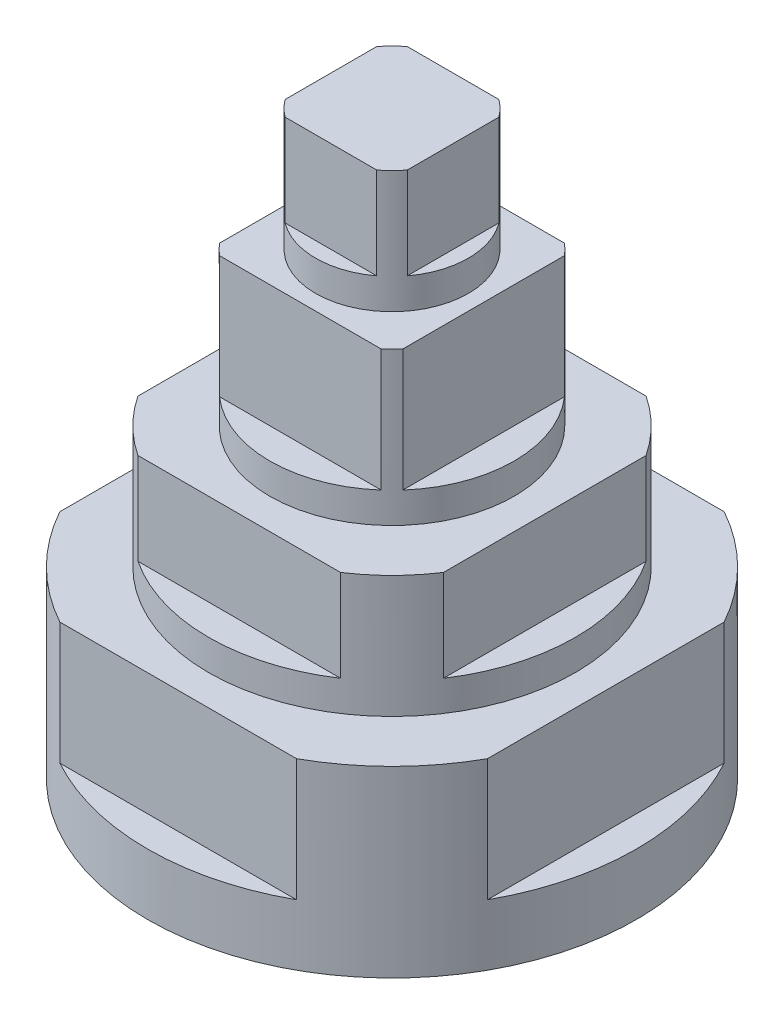
from build123d import *

# Parameters (mm, degrees)
SKETCH1_R           = 40
BOSS_EXTRUDE1_DEPTH = 30
SKETCH2_R           = 30
BOSS_EXTRUDE2_DEPTH = 20
SKETCH3_R           = 20
BOSS_EXTRUDE3_DEPTH = 25
SKETCH4_R           = 12.5
BOSS_EXTRUDE4_DEPTH = 20
SKETCH5_OUTSIDE_W   = 111.546
SKETCH5_OUTSIDE_H   = 111.546
SKETCH5_OUTSIDE_W_2 = 20
SKETCH5_OUTSIDE_H_2 = 20
CUT_EXTRUDE2_DEPTH  = 15
CUT_EXTRUDE7_DEPTH  = 20
CUT_EXTRUDE8_START  = 50
CUT_EXTRUDE8_DEPTH  = 15
CUT_EXTRUDE9_DEPTH  = 20


with BuildPart() as part:
    # Sketch1 → Boss-Extrude1 (new body)
    with BuildSketch(Plane(origin=(0, 0, 0), x_dir=(1, 0, 0), z_dir=(0, 1, 0))):
        Circle(SKETCH1_R)
    extrude(amount=BOSS_EXTRUDE1_DEPTH)

    # Sketch2 → Boss-Extrude2 (add)
    with BuildSketch(Plane(origin=(0, 30, 0), x_dir=(1, 0, 0), z_dir=(0, 1, 0))):
        Circle(SKETCH2_R)
    extrude(amount=BOSS_EXTRUDE2_DEPTH)

    # Sketch3 → Boss-Extrude3 (add)
    with BuildSketch(Plane(origin=(0, 50, 0), x_dir=(1, 0, 0), z_dir=(0, 1, 0))):
        Circle(SKETCH3_R)
    extrude(amount=BOSS_EXTRUDE3_DEPTH)

    # Sketch4 → Boss-Extrude4 (add)
    with BuildSketch(Plane(origin=(0, 75, 0), x_dir=(1, 0, 0), z_dir=(0, 1, 0))):
        Circle(SKETCH4_R)
    extrude(amount=BOSS_EXTRUDE4_DEPTH)

    # Sketch5 outside → Cut-Extrude2 (cut)
    with BuildSketch(Plane(origin=(0, 95, 0), x_dir=(1, 0, 0), z_dir=(0, 1, 0))):
        Rectangle(SKETCH5_OUTSIDE_W, SKETCH5_OUTSIDE_H)
        Rectangle(SKETCH5_OUTSIDE_W_2, SKETCH5_OUTSIDE_H_2, mode=Mode.SUBTRACT)
    extrude(amount=-CUT_EXTRUDE2_DEPTH, mode=Mode.SUBTRACT)

    # Sketch6 → Cut-Extrude7 (cut)
    with BuildSketch(Plane(origin=(0, 75, 0), x_dir=(1, 0, 0), z_dir=(0, 1, 0))):
        Polygon((-5.77591504, 20.949618127), (-15, 15), (15, 15), (14.22408496, 20.949618127), align=None)
        Polygon((-15, -15), (-15, 15), (-20.949618127, 14.22408496), (-20.949618127, -5.77591504), align=None)
        Polygon((20.949618127, 5.77591504), (15, 15), (15, -15), (20.949618127, -14.22408496), align=None)
        Polygon((15, -15), (-15, -15), (-14.22408496, -20.949618127), (5.77591504, -20.949618127), align=None)
    extrude(amount=-CUT_EXTRUDE7_DEPTH, mode=Mode.SUBTRACT)

    # Sketch7 → Cut-Extrude8 (cut)
    with BuildSketch(Plane(origin=(0, 0, 0), x_dir=(1, 0, 0), z_dir=(0, 1, 0)).offset(CUT_EXTRUDE8_START)):
        with BuildLine():
            Line((-24.918588748, 25), (24.918588748, 25))
            ThreePointArc((24.918588748, 25), (0, 35.297819553), (-24.918588748, 25))
        make_face()
        with BuildLine():
            Line((25, 24.918588748), (25, -24.918588748))
            ThreePointArc((25, -24.918588748), (35.297819553, 0), (25, 24.918588748))
        make_face()
        with BuildLine():
            Line((24.918588748, -25), (-24.918588748, -25))
            ThreePointArc((-24.918588748, -25), (0, -35.297819553), (24.918588748, -25))
        make_face()
        with BuildLine():
            Line((-25, -24.918588748), (-25, 24.918588748))
            ThreePointArc((-25, 24.918588748), (-35.297819553, 0), (-25, -24.918588748))
        make_face()
    extrude(amount=-CUT_EXTRUDE8_DEPTH, mode=Mode.SUBTRACT)

    # Sketch8 → Cut-Extrude9 (cut)
    with BuildSketch(Plane(origin=(0, 30, 0), x_dir=(1, 0, 0), z_dir=(0, 1, 0))):
        with BuildLine():
            Line((-35, 35.707142143), (-35, 35))
            Line((-35, 35), (35, 35))
            Line((35, 35), (35, 35.707142143))
            ThreePointArc((35, 35.707142143), (0, 50), (-35, 35.707142143))
        make_face()
        with BuildLine():
            Line((-35, 35), (-35.707142143, 35))
            ThreePointArc((-35.707142143, 35), (-50, 0), (-35.707142143, -35))
            Line((-35.707142143, -35), (-35, -35))
            Line((-35, -35), (-35, 35))
        make_face()
        with BuildLine():
            Line((35.707142143, 35), (35, 35))
            Line((35, 35), (35, -35))
            Line((35, -35), (35.707142143, -35))
            ThreePointArc((35.707142143, -35), (50, 0), (35.707142143, 35))
        make_face()
        with BuildLine():
            Line((35, -35), (-35, -35))
            Line((-35, -35), (-35, -35.707142143))
            ThreePointArc((-35, -35.707142143), (0, -50), (35, -35.707142143))
            Line((35, -35.707142143), (35, -35))
        make_face()
    extrude(amount=-CUT_EXTRUDE9_DEPTH, mode=Mode.SUBTRACT)


solid = part.part
